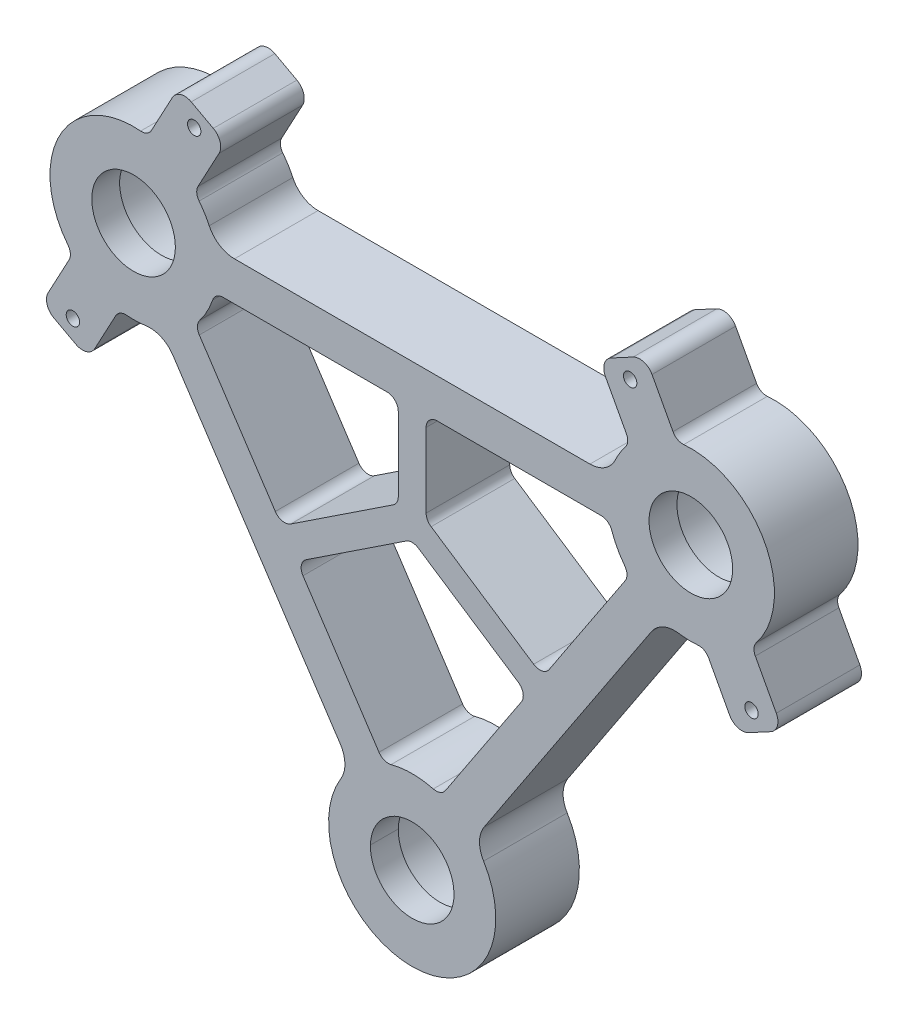
from build123d import *

# Parameters (mm, degrees)
BOSS_EXTRUDE1_DEPTH           = 7.5
FILLET1_R                     = 2
FILLET2_R                     = 5
CHAMFER1_SIZE                 = 1
M2_5_TAPPED_HOLE1_D           = 2.4
M2_5_TAPPED_HOLE1_CSINK_D     = 3
M2_5_TAPPED_HOLE1_CSINK_ANGLE = 90


with BuildPart() as part:
    # Sketch1 → Boss-Extrude1 (new body, symmetric)
    with BuildSketch(Plane.XY):
        with BuildLine():
            Line((10.96838323, -65.321653098), (44.869098301, -14.095171079))
            ThreePointArc((44.869098301, -14.095171079), (48.66504531, -14.940478439), (52.550723574, -14.781536092))
            Line((52.550723574, -14.781536092), (56.963282689, -22.992992284))
            ThreePointArc((56.963282689, -22.992992284), (58.445062856, -24.203567674), (60.348845726, -24.011796937))
            Line((60.348845726, -24.011796937), (64.312776647, -21.88171439))
            ThreePointArc((64.312776647, -21.88171439), (65.523352037, -20.399934224), (65.331581299, -18.496151353))
            Line((65.331581299, -18.496151353), (60.919022184, -10.284695161))
            ThreePointArc((60.919022184, -10.284695161), (63.213103069, 7.100275156), (47.449276426, 14.781536092))
            Line((47.449276426, 14.781536092), (43.036717311, 22.992992284))
            ThreePointArc((43.036717311, 22.992992284), (41.554937144, 24.203567674), (39.651154274, 24.011796937))
            Line((39.651154274, 24.011796937), (35.687223353, 21.88171439))
            ThreePointArc((35.687223353, 21.88171439), (34.476647963, 20.399934224), (34.668418701, 18.496151353))
            Line((34.668418701, 18.496151353), (39.080977816, 10.284695161))
            ThreePointArc((39.080977816, 10.284695161), (36.804017619, 7.132043817), (35.414047854, 3.5))
            Line((35.414047854, 3.5), (-35.414047854, 3.5))
            ThreePointArc((-35.414047854, 3.5), (-36.804017619, 7.132043817), (-39.080977816, 10.284695161))
            Line((-39.080977816, 10.284695161), (-34.668418701, 18.496151353))
            ThreePointArc((-34.668418701, 18.496151353), (-34.476647963, 20.399934224), (-35.687223353, 21.88171439))
            Line((-35.687223353, 21.88171439), (-39.651154274, 24.011796937))
            ThreePointArc((-39.651154274, 24.011796937), (-41.554937144, 24.203567674), (-43.036717311, 22.992992284))
            Line((-43.036717311, 22.992992284), (-47.449276426, 14.781536092))
            ThreePointArc((-47.449276426, 14.781536092), (-63.213103069, 7.100275156), (-60.919022184, -10.284695161))
            Line((-60.919022184, -10.284695161), (-65.331581299, -18.496151353))
            ThreePointArc((-65.331581299, -18.496151353), (-65.523352037, -20.399934224), (-64.312776647, -21.88171439))
            Line((-64.312776647, -21.88171439), (-60.348845726, -24.011796937))
            ThreePointArc((-60.348845726, -24.011796937), (-58.445062856, -24.203567674), (-56.963282689, -22.992992284))
            Line((-56.963282689, -22.992992284), (-52.550723574, -14.781536092))
            ThreePointArc((-52.550723574, -14.781536092), (-48.66504531, -14.940478439), (-44.869098301, -14.095171079))
            Line((-44.869098301, -14.095171079), (-10.96838323, -65.321653098))
            ThreePointArc((-10.96838323, -65.321653098), (0, -90.553689519), (10.96838323, -65.321653098))
        make_face()
        with BuildLine():
            Line((39.03161677, -10.232036421), (23.460950184, -33.760462599))
            Line((23.460950184, -33.760462599), (2.5, -19.888902972))
            Line((2.5, -19.888902972), (2.5, -3.5))
            Line((2.5, -3.5), (35.414047854, -3.5))
            ThreePointArc((35.414047854, -3.5), (36.786896931, -7.100275156), (39.03161677, -10.232036421))
        make_face(mode=Mode.SUBTRACT)
        with BuildLine():
            Line((-35.414047854, -3.5), (-2.5, -3.5))
            Line((-2.5, -3.5), (-2.5, -19.888902972))
            Line((-2.5, -19.888902972), (-23.460950184, -33.760462599))
            Line((-23.460950184, -33.760462599), (-39.03161677, -10.232036421))
            ThreePointArc((-39.03161677, -10.232036421), (-36.786896931, -7.100275156), (-35.414047854, -3.5))
        make_face(mode=Mode.SUBTRACT)
        with BuildLine():
            Line((-20.701568286, -37.930092263), (0, -24.230186661))
            Line((0, -24.230186661), (20.701568286, -37.930092263))
            Line((20.701568286, -37.930092263), (5.130901699, -61.45851844))
            ThreePointArc((5.130901699, -61.45851844), (0, -60.553689519), (-5.130901699, -61.45851844))
            Line((-5.130901699, -61.45851844), (-20.701568286, -37.930092263))
        make_face(mode=Mode.SUBTRACT)
    extrude(amount=BOSS_EXTRUDE1_DEPTH, both=True)

    # Fillet1
    fillet1_edges = [part.edges().sort_by_distance(p)[0] for p in [
        (-35.414047854, -3.5, 0),
        (-39.03161677, -10.232036421, 0),
        (-23.460950184, -33.760462599, 0),
        (-2.5, -19.888902972, 0),
        (-2.5, -3.5, 0),
        (-52.550723574, -14.781536092, 0),
        (-60.919022184, -10.284695161, 0),
        (-47.449276426, 14.781536092, 0),
        (-39.080977816, 10.284695161, 0),
        (39.080977816, 10.284695161, 0),
        (47.449276426, 14.781536092, 0),
        (60.919022184, -10.284695161, 0),
        (52.550723574, -14.781536092, 0),
        (39.03161677, -10.232036421, 0),
        (35.414047854, -3.5, 0),
        (2.5, -3.5, 0),
        (2.5, -19.888902972, 0),
        (23.460950184, -33.760462599, 0),
        (-5.130901699, -61.45851844, 0),
        (5.130901699, -61.45851844, 0),
        (20.701568286, -37.930092263, 0),
        (0, -24.230186661, 0),
        (-20.701568286, -37.930092263, 0),
    ]]
    fillet(fillet1_edges, radius=FILLET1_R)

    # Fillet2
    fillet2_edges = [part.edges().sort_by_distance(p)[0] for p in [
        (-10.96838323, -65.321653098, 0),
        (-44.869098301, -14.095171079, 0),
        (-35.414047854, 3.5, 0),
        (35.414047854, 3.5, 0),
        (44.869098301, -14.095171079, 0),
        (10.96838323, -65.321653098, 0),
    ]]
    fillet(fillet2_edges, radius=FILLET2_R)

    # Sketch6 → Cut-Revolve1 (revolve, cut)
    with BuildSketch(Plane(origin=(-50, 0, 0), x_dir=(0, 0, -1), z_dir=(1, 0, 0))):
        Polygon((-7.5, 0), (-7.5, 7.5), (-2.5, 7.5), (-2.5, 9.5), (7.5, 9.5), (7.5, 0), align=None)
    revolve(axis=Axis((-50, 0, 7.5), (0, 0, -1)), mode=Mode.SUBTRACT)

    # Sketch7 → Cut-Revolve2 (revolve, cut)
    with BuildSketch(Plane(origin=(50, 0, 0), x_dir=(0, 0, -1), z_dir=(1, 0, 0))):
        Polygon((7.5, 0), (-7.5, 0), (-7.5, 7.5), (-2.5, 7.5), (-2.5, 9.5), (7.5, 9.5), align=None)
    revolve(axis=Axis((50, 0, 7.5), (0, 0, -1)), mode=Mode.SUBTRACT)

    # Sketch8 → Cut-Revolve3 (revolve, cut)
    with BuildSketch(Plane(origin=(0, 0, 0), x_dir=(0, 0, -1), z_dir=(1, 0, 0))):
        Polygon((7.5, -75.553689519), (-15.002177418, -75.553689519), (-7.5, -83.053689519), (-2.5, -83.053689519), (-2.5, -85.053689519), (7.5, -85.053689519), align=None)
    revolve(axis=Axis((0, -75.553689519, 7.5), (0, 0, -1)), mode=Mode.SUBTRACT)

    # Chamfer1
    chamfer1_edges = [part.edges().sort_by_distance(p)[0] for p in [
        (-50, -9.5, -7.5),
        (50, -9.5, -7.5),
        (0, -66.053689519, -7.5),
    ]]
    chamfer(chamfer1_edges, length=CHAMFER1_SIZE)

    # M2.5 Tapped Hole1 (through all)
    with Locations(Plane(origin=(0, 0, -7.5), x_dir=(-1, 0, 0), z_dir=(0, 0, -1))):
        with Locations((-39.112911428, 20.260091373), (-60.887088572, -20.260091373), (39.112911428, 20.260091373), (60.887088572, -20.260091373)):
            CounterSinkHole(M2_5_TAPPED_HOLE1_D / 2, M2_5_TAPPED_HOLE1_CSINK_D / 2, counter_sink_angle=M2_5_TAPPED_HOLE1_CSINK_ANGLE)


solid = part.part
